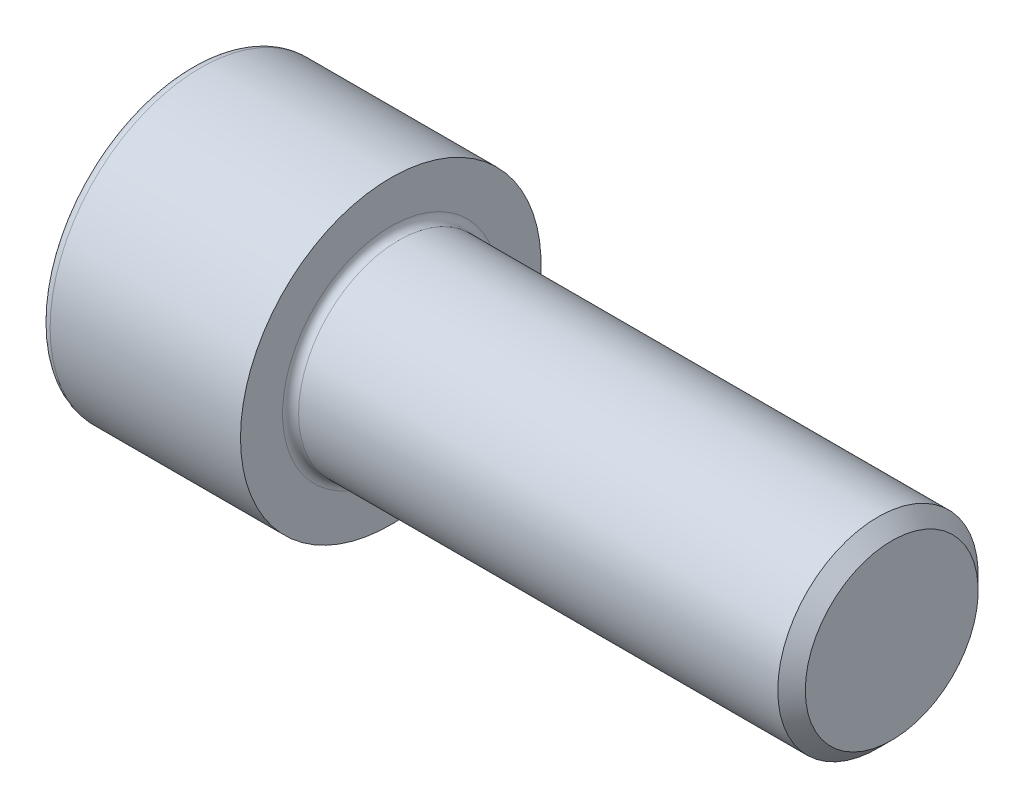
from build123d import *

# Parameters (mm, degrees)
FILLET1_R   = 0.8
FILLET2_R   = 1
HEX_2_DEPTH = 10


with BuildPart() as part:
    # BodySke → Base-Revolve (revolve)
    with BuildSketch(Plane.XY):
        Polygon((0, 0), (0, 15), (20, 15), (20, 10), (68.626, 10), (70, 8.626), (70, 0), align=None)
    revolve(axis=Axis((-31.75, 0, 0), (1, 0, 0)))

    # Fillet1
    fillet1_edges = [part.edges().sort_by_distance(p)[0] for p in [
        (20, -10, 0),
    ]]
    fillet(fillet1_edges, radius=FILLET1_R)

    # Fillet2
    fillet2_edges = [part.edges().sort_by_distance(p)[0] for p in [
        (0, -15, 0),
    ]]
    fillet(fillet2_edges, radius=FILLET2_R)

    # Sketch2 → Hex-PreBroach (revolve, cut)
    with BuildSketch(Plane.XY):
        Polygon((0, 8.615), (10, 8.615), (14.973872569, 0), (0, 0), align=None)
    revolve(axis=Axis((0, 0, 0), (1, 0, 0)), mode=Mode.SUBTRACT)

    # Sketch3 → Hex 2 (cut)
    with BuildSketch(Plane(origin=(0, 0, 0), x_dir=(0, 0.5, 0.866025404), z_dir=(-1, 0, 0))):
        Polygon((4.973872569, 8.615), (-4.973872569, 8.615), (-9.947745138, 0), (-4.973872569, -8.615), (4.973872569, -8.615), (9.947745138, 0), align=None)
    extrude(amount=-HEX_2_DEPTH, mode=Mode.SUBTRACT)


solid = part.part
